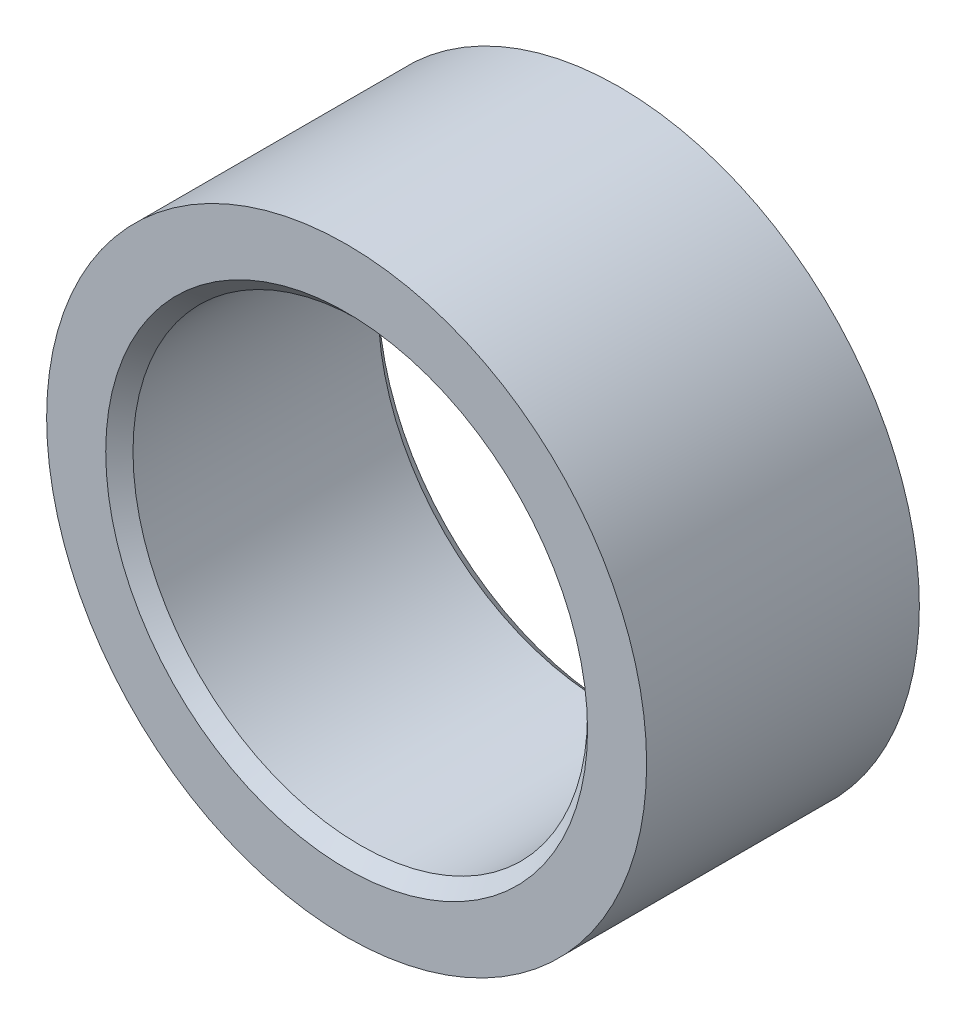
from build123d import *

# Parameters (mm, degrees)
SKETCH1_R           = 6.6
SKETCH1_R_2         = 5
BOSS_EXTRUDE1_DEPTH = 3
CHAMFER1_SIZE       = 0.3


with BuildPart() as part:
    # Sketch1 → Boss-Extrude1 (new body, symmetric)
    with BuildSketch(Plane.XY):
        Circle(SKETCH1_R)
        Circle(SKETCH1_R_2, mode=Mode.SUBTRACT)
    extrude(amount=BOSS_EXTRUDE1_DEPTH, both=True)

    # Chamfer1
    chamfer1_edges = [part.edges().sort_by_distance(p)[0] for p in [
        (-5, 0, -3),
        (-5, 0, 3),
    ]]
    chamfer(chamfer1_edges, length=CHAMFER1_SIZE)


solid = part.part
